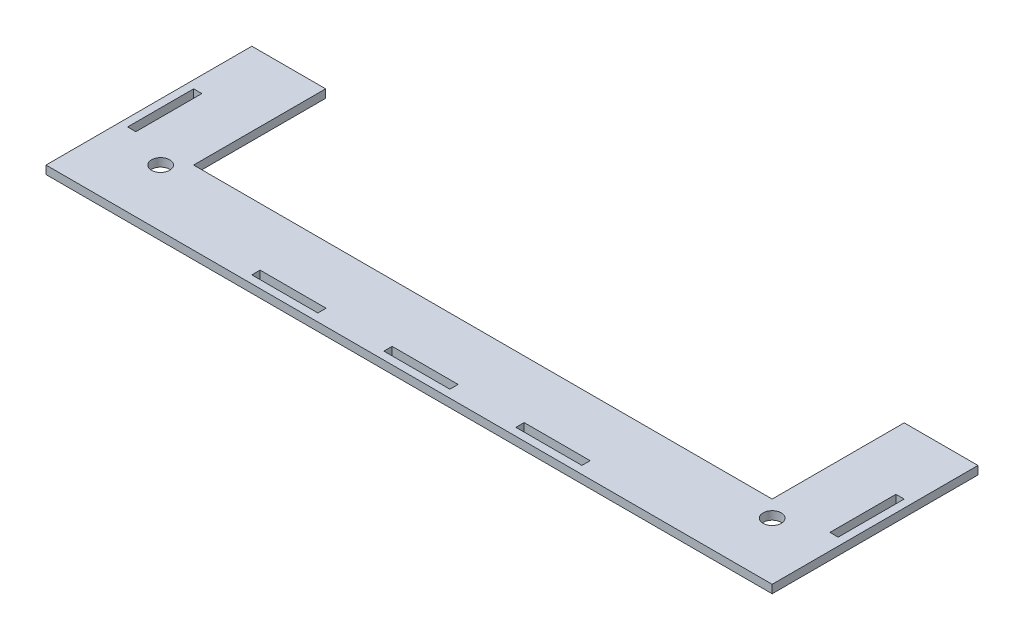
from build123d import *

# Parameters (mm, degrees)
SKETCH1_W           = 3.175
SKETCH1_H           = 25.4
SKETCH1_W_2         = 25.4
SKETCH1_H_2         = 3.175
SKETCH1_R           = 3.5
BOSS_EXTRUDE1_DEPTH = 3.175


with BuildPart() as part:
    # Sketch1 → Boss-Extrude1 (new body)
    with BuildSketch(Plane(origin=(0, 0, 0), x_dir=(1, 0, 0), z_dir=(0, 1, 0))):
        Polygon((-111.3, 63.5), (-139.7, 63.5), (-139.7, -15.7), (139.7, -15.7), (139.7, 63.5), (111.3, 63.5), (111.3, 12.7), (-111.3, 12.7), align=None)
        with Locations((135.1125, 25.4)):
            Rectangle(SKETCH1_W, SKETCH1_H, mode=Mode.SUBTRACT)
        with Locations((50.8, -11.1125)):
            Rectangle(SKETCH1_W_2, SKETCH1_H_2, mode=Mode.SUBTRACT)
        with Locations((0, -11.1125)):
            Rectangle(SKETCH1_W_2, SKETCH1_H_2, mode=Mode.SUBTRACT)
        with Locations((-50.8, -11.1125)):
            Rectangle(SKETCH1_W_2, SKETCH1_H_2, mode=Mode.SUBTRACT)
        with Locations((-135.1125, 25.4)):
            Rectangle(SKETCH1_W, SKETCH1_H, mode=Mode.SUBTRACT)
        with Locations((-117.65, 6.35)):
            Circle(SKETCH1_R, mode=Mode.SUBTRACT)
        with Locations((117.65, 6.35)):
            Circle(SKETCH1_R, mode=Mode.SUBTRACT)
    extrude(amount=BOSS_EXTRUDE1_DEPTH)


solid = part.part
